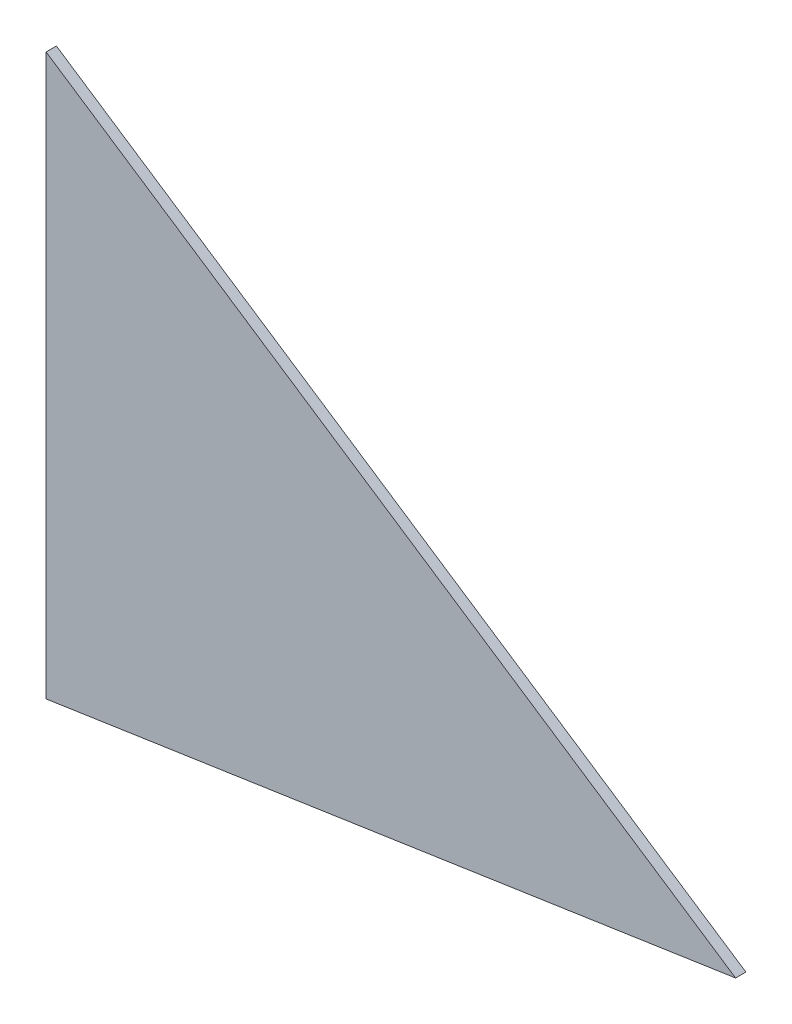
from build123d import *

# Parameters (mm, degrees)
DODANIE_WYCI_GNI_CIE1_DEPTH = 10


with BuildPart() as part:
    # Szkic1 → Dodanie-wyciągnięcie1 (new body)
    with BuildSketch(Plane.XY):
        Polygon((-233.875284897, -176.840766639), (-903.923901621, -277.009091385), (-903.923901621, 267.525330512), align=None)
    extrude(amount=DODANIE_WYCI_GNI_CIE1_DEPTH)


solid = part.part
